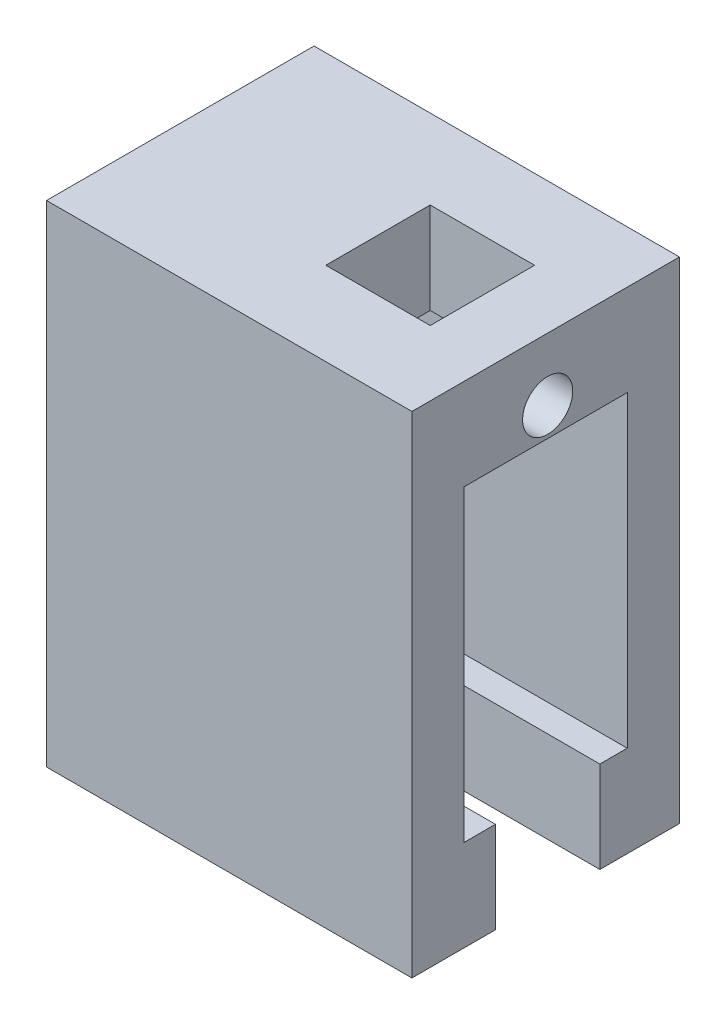
from build123d import *

# Parameters (mm, degrees)
SKETCH1_W           = 20.5
SKETCH1_H           = 37.6
SKETCH1_W_2         = 12.5
SKETCH1_H_2         = 23.6
BOSS_EXTRUDE1_DEPTH = 28
SKETCH2_R           = 1.92
CUT_EXTRUDE1_DEPTH  = 13
SKETCH3_W           = 8
SKETCH3_H           = 7
CUT_EXTRUDE2_DEPTH  = 8
SKETCH4_W           = 8
SKETCH4_H           = 7
CUT_EXTRUDE3_DEPTH  = 20


with BuildPart() as part:
    # Sketch1 → Boss-Extrude1 (new body)
    with BuildSketch(Plane(origin=(0, 0, 0), x_dir=(0, 0, -1), z_dir=(1, 0, 0))):
        with Locations((-0.15, -0.55)):
            Rectangle(SKETCH1_W, SKETCH1_H)
        with Locations((-0.15, -0.55)):
            Rectangle(SKETCH1_W_2, SKETCH1_H_2, mode=Mode.SUBTRACT)
    extrude(amount=BOSS_EXTRUDE1_DEPTH)

    # Sketch2 → Cut-Extrude1 (cut)
    with BuildSketch(Plane(origin=(28, 0, 0), x_dir=(0, 0, -1), z_dir=(1, 0, 0))):
        with Locations((0, 13.45)):
            Circle(SKETCH2_R)
    extrude(amount=-CUT_EXTRUDE1_DEPTH, mode=Mode.SUBTRACT)

    # Sketch3 → Cut-Extrude2 (cut)
    with BuildSketch(Plane(origin=(15, 0, 0), x_dir=(0, 0, -1), z_dir=(1, 0, 0))):
        with Locations((0, 14.75)):
            Rectangle(SKETCH3_W, SKETCH3_H)
    extrude(amount=CUT_EXTRUDE2_DEPTH, mode=Mode.SUBTRACT)

    # Sketch4 → Cut-Extrude3 (cut)
    with BuildSketch(Plane(origin=(28, 0, 0), x_dir=(0, 0, -1), z_dir=(1, 0, 0))):
        with Locations((0, -15.85)):
            Rectangle(SKETCH4_W, SKETCH4_H)
    extrude(amount=-CUT_EXTRUDE3_DEPTH, mode=Mode.SUBTRACT)


solid = part.part
